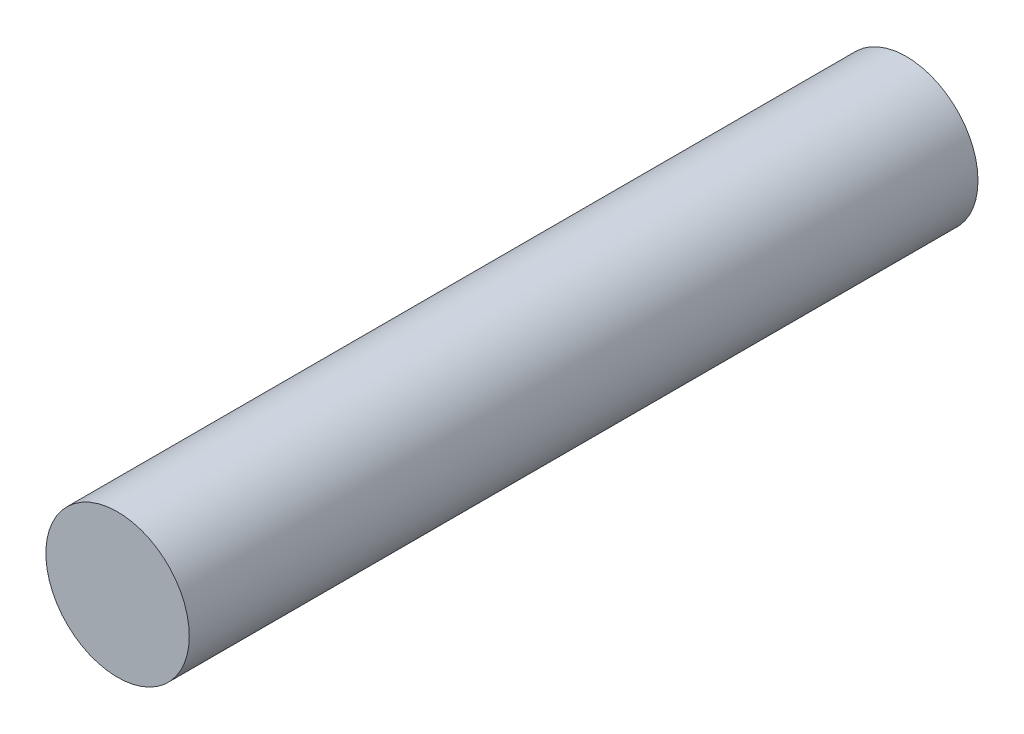
from build123d import *

# Parameters (mm, degrees)
SKETCH1_R           = 3
BOSS_EXTRUDE1_DEPTH = 33


with BuildPart() as part:
    # Sketch1 → Boss-Extrude1 (new body)
    with BuildSketch(Plane.XY):
        Circle(SKETCH1_R)
    extrude(amount=BOSS_EXTRUDE1_DEPTH)


solid = part.part
